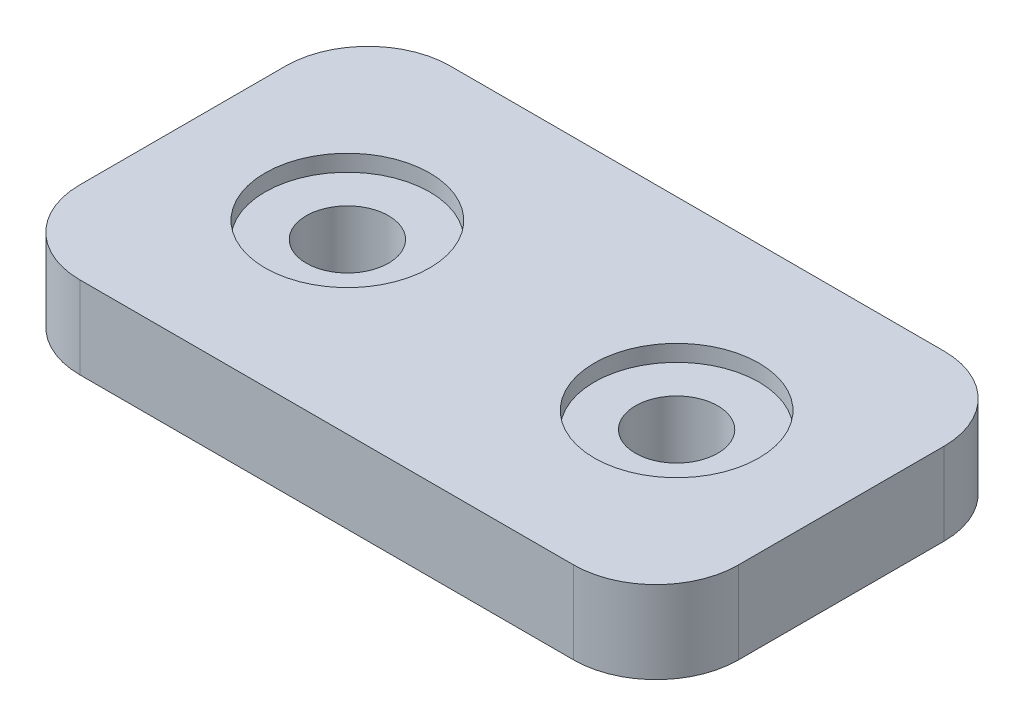
from build123d import *

# Parameters (mm, degrees)
SKETCH1_W           = 101.6
SKETCH1_H           = 57.15
BOSS_EXTRUDE1_DEPTH = 12.7
SKETCH2_R           = 6.35
CUT_EXTRUDE1_DEPTH  = 12.7
SKETCH2_3_R         = 12.7
SKETCH2_3_R_2       = 6.35
CUT_EXTRUDE2_DEPTH  = 2.54
FILLET1_R           = 12.7


with BuildPart() as part:
    # Sketch1 → Boss-Extrude1 (new body)
    with BuildSketch(Plane(origin=(0, 0, 0), x_dir=(1, 0, 0), z_dir=(0, 1, 0))):
        Rectangle(SKETCH1_W, SKETCH1_H)
    extrude(amount=BOSS_EXTRUDE1_DEPTH)

    # Sketch2 → Cut-Extrude1 (cut)
    with BuildSketch(Plane(origin=(0, 12.7, 0), x_dir=(1, 0, 0), z_dir=(0, 1, 0))):
        with Locations((-25.4, 0)):
            Circle(SKETCH2_R)
        with Locations((25.4, 0)):
            Circle(SKETCH2_R)
    extrude(amount=-CUT_EXTRUDE1_DEPTH, mode=Mode.SUBTRACT)

    # Sketch2_3 → Cut-Extrude2 (cut)
    # profile 1 of 2: a face of its own
    with BuildSketch(Plane(origin=(0, 12.7, 0), x_dir=(1, 0, 0), z_dir=(0, 1, 0))):
        with Locations((-25.4, 0)):
            Circle(SKETCH2_3_R)
        with Locations((-25.4, 0)):
            Circle(SKETCH2_3_R_2, mode=Mode.SUBTRACT)
    # profile 2 of 2: a face of its own
    with BuildSketch(Plane(origin=(0, 12.7, 0), x_dir=(1, 0, 0), z_dir=(0, 1, 0))):
        with Locations((25.4, 0)):
            Circle(SKETCH2_3_R)
        with Locations((25.4, 0)):
            Circle(SKETCH2_3_R_2, mode=Mode.SUBTRACT)
    extrude(amount=-CUT_EXTRUDE2_DEPTH, mode=Mode.SUBTRACT)

    # Fillet1
    fillet1_edges = [part.edges().sort_by_distance(p)[0] for p in [
        (50.8, 6.35, -28.575),
        (-50.8, 6.35, -28.575),
        (50.8, 6.35, 28.575),
        (-50.8, 6.35, 28.575),
    ]]
    fillet(fillet1_edges, radius=FILLET1_R)


solid = part.part
